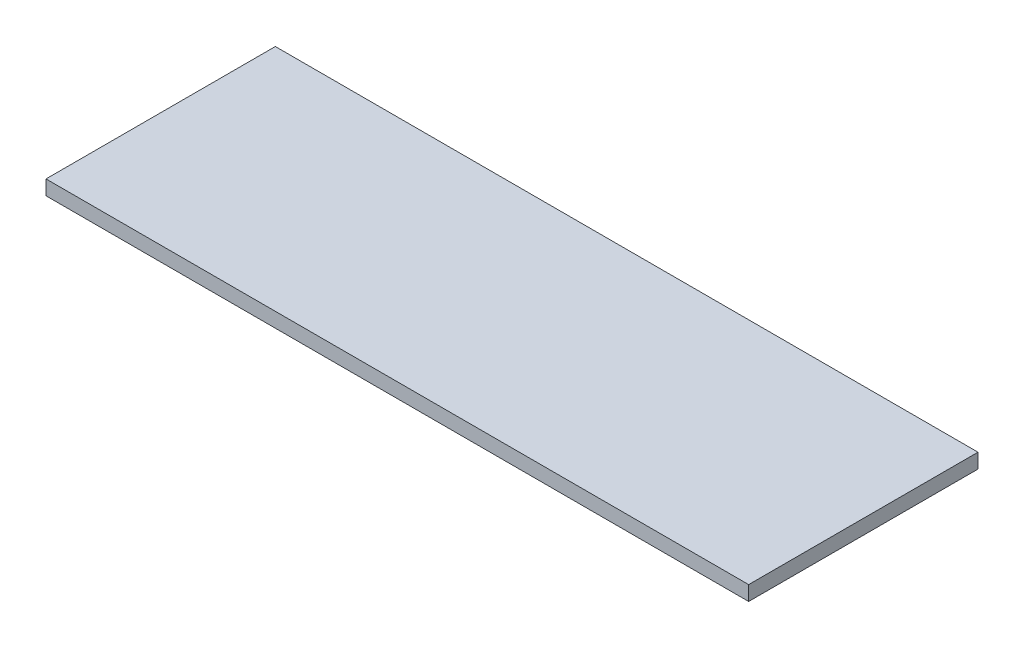
from build123d import *

# Parameters (mm, degrees)
SKETCH1_W           = 288
SKETCH1_H           = 94
BOSS_EXTRUDE1_DEPTH = 6


with BuildPart() as part:
    # Sketch1 → Boss-Extrude1 (new body)
    with BuildSketch(Plane(origin=(0, 0, 0), x_dir=(1, 0, 0), z_dir=(0, 1, 0))):
        with Locations((144, 47)):
            Rectangle(SKETCH1_W, SKETCH1_H)
    extrude(amount=BOSS_EXTRUDE1_DEPTH)


solid = part.part
